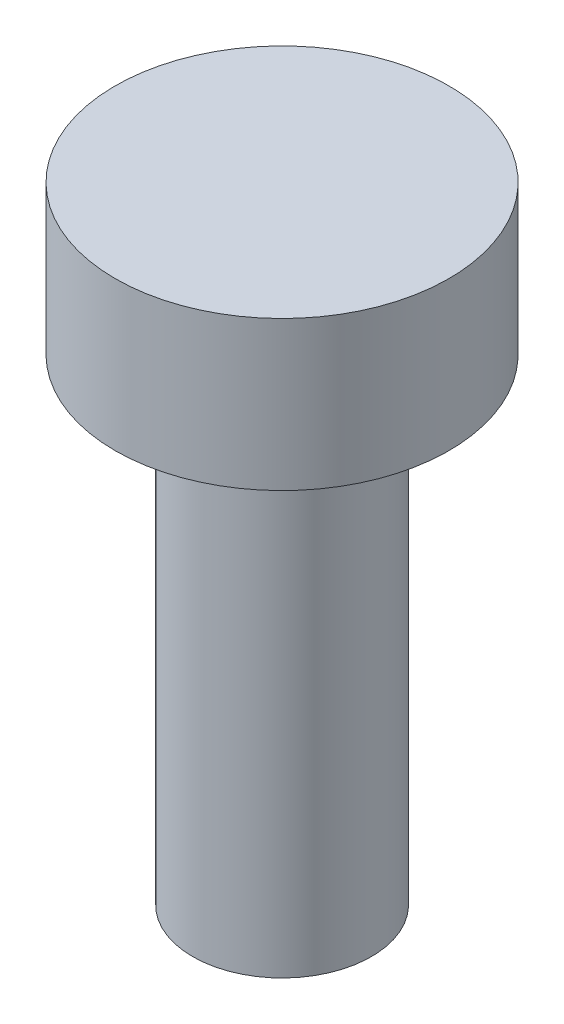
from build123d import *

# Parameters (mm, degrees)
SKETCH1_R           = 1.5
BOSS_EXTRUDE1_DEPTH = 8
SKETCH2_R           = 2.8
BOSS_EXTRUDE2_DEPTH = 2.5


with BuildPart() as part:
    # Sketch1 → Boss-Extrude1 (new body)
    with BuildSketch(Plane(origin=(0, 0, 0), x_dir=(1, 0, 0), z_dir=(0, 1, 0))):
        Circle(SKETCH1_R)
    extrude(amount=BOSS_EXTRUDE1_DEPTH)

    # Sketch2 → Boss-Extrude2 (add)
    with BuildSketch(Plane(origin=(0, 8, 0), x_dir=(1, 0, 0), z_dir=(0, 1, 0))):
        Circle(SKETCH2_R)
    extrude(amount=BOSS_EXTRUDE2_DEPTH)


solid = part.part
